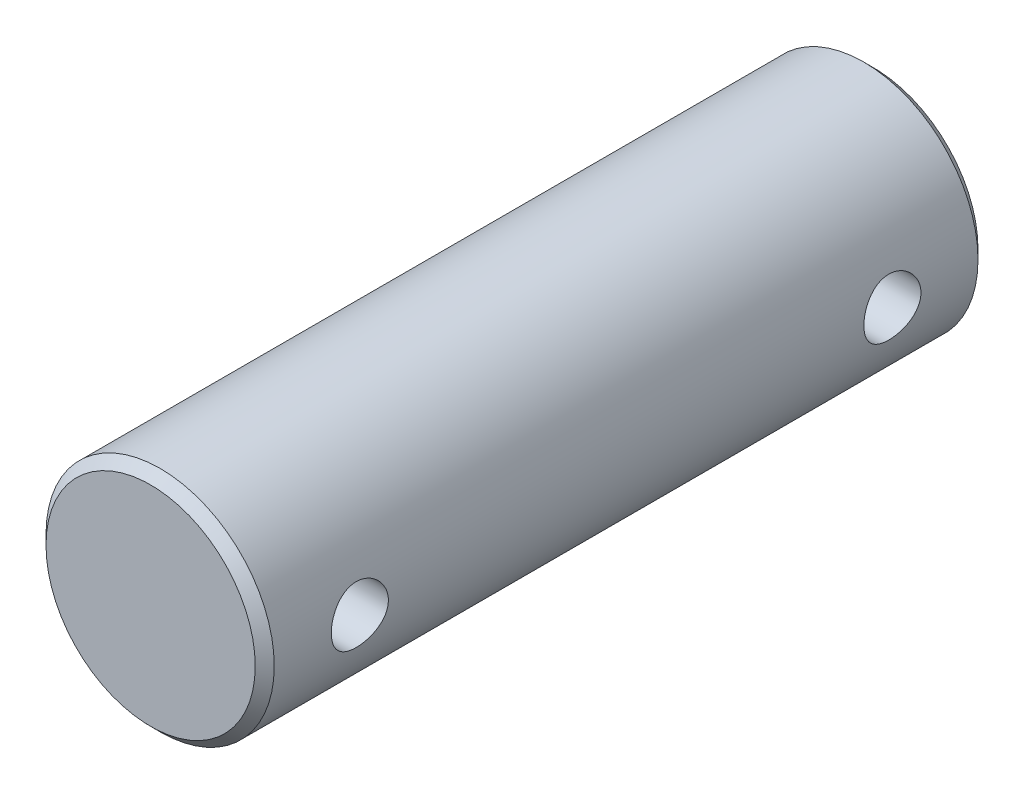
from build123d import *

# Parameters (mm, degrees)
SKETCH3_R               = 3
BOSS_EXTRUDE1_DEPTH     = 19
SKETCH4_R               = 0.75
CUT_EXTRUDE1_DEPTH      = 4
CUT_EXTRUDE1_DEPTH_BACK = 4
CHAMFER1_SIZE           = 0.25


with BuildPart() as part:
    # Sketch3 → Boss-Extrude1 (new body)
    with BuildSketch(Plane.XY):
        Circle(SKETCH3_R)
    extrude(amount=BOSS_EXTRUDE1_DEPTH)

    # Sketch4 → Cut-Extrude1 (cut, two sides)
    with BuildSketch(Plane(origin=(0, 0, 0), x_dir=(0, 0, -1), z_dir=(1, 0, 0))) as cut_extrude1_sk:
        with Locations((-2.5, 0)):
            Circle(SKETCH4_R)
        with Locations((-16.5, 0)):
            Circle(SKETCH4_R)
    extrude(amount=CUT_EXTRUDE1_DEPTH, mode=Mode.SUBTRACT)
    extrude(cut_extrude1_sk.sketch, amount=-CUT_EXTRUDE1_DEPTH_BACK, mode=Mode.SUBTRACT)

    # Chamfer1
    chamfer1_edges = [part.edges().sort_by_distance(p)[0] for p in [
        (-3, 0, 0),
        (-3, 0, 19),
    ]]
    chamfer(chamfer1_edges, length=CHAMFER1_SIZE)


solid = part.part
